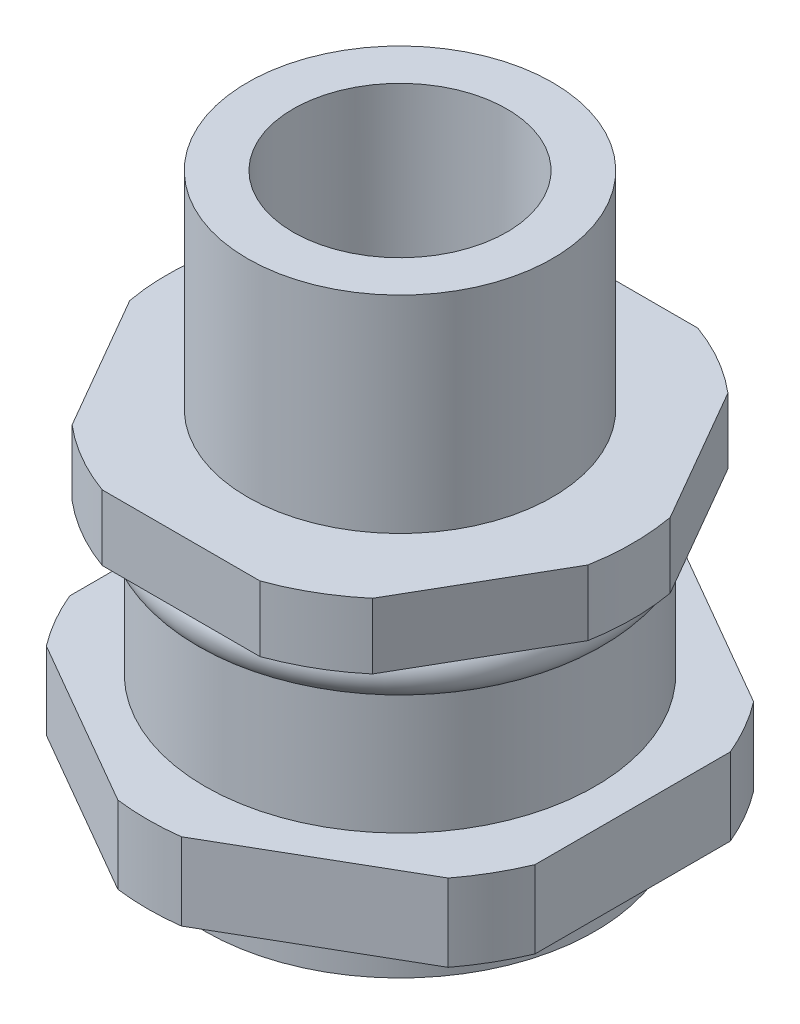
from build123d import *

# Parameters (mm, degrees)
SKETCH2_R           = 5.91185
BOSS_EXTRUDE1_DEPTH = 8.001
SKETCH3_R           = 9.017
BOSS_EXTRUDE2_DEPTH = 2.54
CUT_EXTRUDE1_DEPTH  = 2.54
SKETCH5_R           = 7.5565
BOSS_EXTRUDE3_DEPTH = 11.2141
SKETCH6_R           = 0.889
BOSS_EXTRUDE4_START = 6.35
BOSS_EXTRUDE4_DEPTH = 2.9972
SKETCH8_R           = 4.1402
CUT_EXTRUDE2_DEPTH  = 8.001


with BuildPart() as part:
    # Sketch2 → Boss-Extrude1 (new body)
    with BuildSketch(Plane(origin=(0, 0, 0), x_dir=(1, 0, 0), z_dir=(0, 1, 0))):
        Circle(SKETCH2_R)
    extrude(amount=BOSS_EXTRUDE1_DEPTH)

    # Sketch3 → Boss-Extrude2 (add)
    with BuildSketch(Plane.XZ):
        Circle(SKETCH3_R)
    extrude(amount=BOSS_EXTRUDE2_DEPTH)

    # Sketch4 → Cut-Extrude1 (cut)
    with BuildSketch(Plane(origin=(0, 0, 0), x_dir=(1, 0, 0), z_dir=(0, 1, 0))):
        with BuildLine():
            Line((-3.055293773, 8.4836), (3.055293773, 8.4836))
            ThreePointArc((3.055293773, 8.4836), (0, 9.017), (-3.055293773, 8.4836))
        make_face()
        with BuildLine():
            ThreePointArc((8.874660002, 1.595837976), (7.808951066, 4.5085), (5.819366229, 6.887762024))
            Line((5.819366229, 6.887762024), (8.874660002, 1.595837976))
        make_face()
        with BuildLine():
            Line((-8.874660002, 1.595837976), (-5.819366229, 6.887762024))
            ThreePointArc((-5.819366229, 6.887762024), (-7.808951066, 4.5085), (-8.874660002, 1.595837976))
        make_face()
        with BuildLine():
            ThreePointArc((5.819366229, -6.887762024), (7.808951066, -4.5085), (8.874660002, -1.595837976))
            Line((8.874660002, -1.595837976), (5.819366229, -6.887762024))
        make_face()
        with BuildLine():
            Line((-5.819366229, -6.887762024), (-8.874660002, -1.595837976))
            ThreePointArc((-8.874660002, -1.595837976), (-7.808951066, -4.5085), (-5.819366229, -6.887762024))
        make_face()
        with BuildLine():
            ThreePointArc((-3.055293773, -8.4836), (0, -9.017), (3.055293773, -8.4836))
            Line((3.055293773, -8.4836), (-3.055293773, -8.4836))
        make_face()
    extrude(amount=-CUT_EXTRUDE1_DEPTH, mode=Mode.SUBTRACT)

    # Sketch5 → Boss-Extrude3 (add)
    with BuildSketch(Plane.XZ.offset(2.54)):
        Circle(SKETCH5_R)
    extrude(amount=BOSS_EXTRUDE3_DEPTH)

    # Sketch7 → Boss-Extrude4 (add)
    with BuildSketch(Plane.XZ.offset(2.54).offset(BOSS_EXTRUDE4_START)):
        with BuildLine():
            Line((9.017, -3.784514764), (9.017, 3.784514764))
            ThreePointArc((9.017, 3.784514764), (8.468862424, 4.8895), (7.785985927, 5.916693684))
            Line((7.785985927, 5.916693684), (1.231014073, 9.701208448))
            ThreePointArc((1.231014073, 9.701208448), (0, 9.779), (-1.231014073, 9.701208448))
            Line((-1.231014073, 9.701208448), (-7.785985927, 5.916693684))
            ThreePointArc((-7.785985927, 5.916693684), (-8.468862424, 4.8895), (-9.017, 3.784514764))
            Line((-9.017, 3.784514764), (-9.017, -3.784514764))
            ThreePointArc((-9.017, -3.784514764), (-8.468862424, -4.8895), (-7.785985927, -5.916693684))
            Line((-7.785985927, -5.916693684), (-1.231014073, -9.701208448))
            ThreePointArc((-1.231014073, -9.701208448), (0, -9.779), (1.231014073, -9.701208448))
            Line((1.231014073, -9.701208448), (7.785985927, -5.916693684))
            ThreePointArc((7.785985927, -5.916693684), (8.468862424, -4.8895), (9.017, -3.784514764))
        make_face()
    extrude(amount=BOSS_EXTRUDE4_DEPTH)

    # Sketch8 → Cut-Extrude2 (cut)
    with BuildSketch(Plane(origin=(0, 8.001, 0), x_dir=(1, 0, 0), z_dir=(0, 1, 0))):
        Circle(SKETCH8_R)
    extrude(amount=-CUT_EXTRUDE2_DEPTH, mode=Mode.SUBTRACT)


with BuildPart() as body_2:
    # Sketch6 → Revolve1 (revolve)
    with BuildSketch(Plane.XY):
        with Locations((7.1882, -3.429)):
            Circle(SKETCH6_R)
    revolve(axis=Axis((0, 0, 0), (0, -1, 0)))


solid = Compound([part.part, body_2.part])
